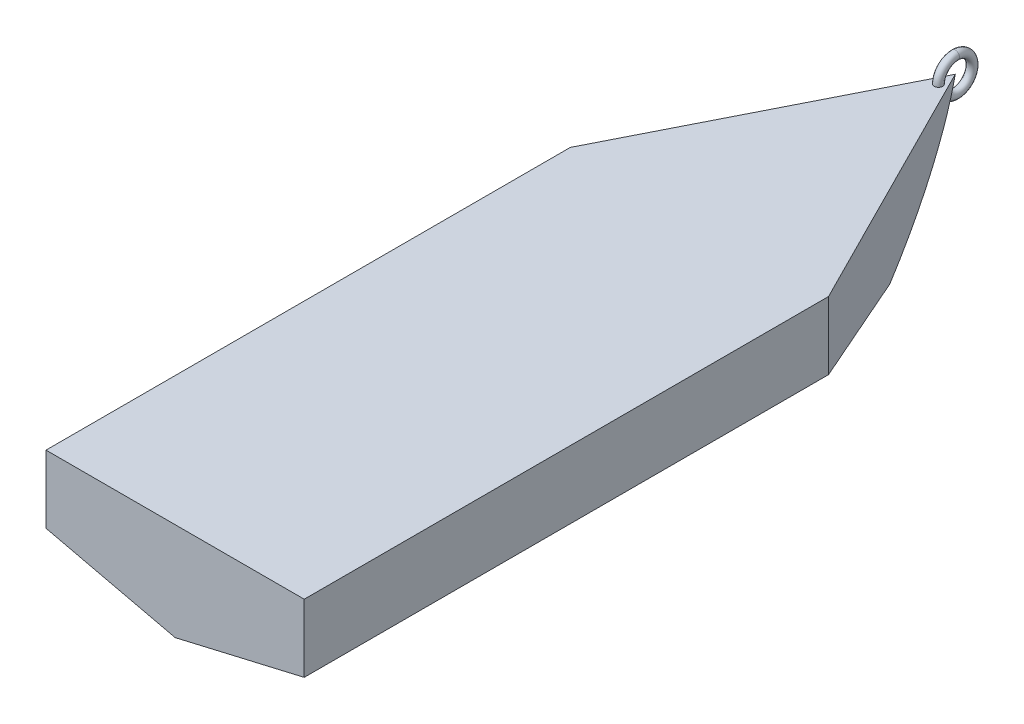
from build123d import *

# Parameters (mm, degrees)
TOP_BOW_EXTRUSION_DEPTH              = 56.86004
PORT_STARBOARD_CUT_DEPTH             = 38.529378828
PORT_STARBOARD_CUT_DEPTH_BACK        = 38.529527124
FORE_AFT_BOW_WRAPUP_EXTRUSTION_REACH = 76.36
SCALE_2_SCALE_X                      = 2
SCALE_2_SCALE_Y                      = 2
SCALE_2_SCALE_Z                      = 2
SHELL2_T                             = 2.54
SCALE1_SCALE_X                       = 0.65
SCALE1_SCALE_Y                       = 0.325
SCALE1_SCALE_Z                       = 0.65
SKETCH2_R                            = 1.5875


with BuildPart() as part:
    # Cross-Section C Sketch → Fore-Aft Loft section 0
    with BuildSketch(Plane.XY.offset(76.2)):
        Polygon((-0.000593186, -30.406404979), (37.528192355, -12.906444879), (37.528192355, 26.453635249), (-37.529378728, 26.453635249), (-37.529378728, -12.906444879), align=None)
    # Cross-Section B Sketch → Fore-Aft Loft section 1
    with BuildSketch(Plane.XY):
        Polygon((-0.000593186, -30.406404979), (37.528192355, -12.906444879), (37.528192355, 26.453635249), (-37.529378728, 26.453635249), (-37.529378728, -12.906444879), align=None)
    # Cross-Section A Sketch → Fore-Aft Loft section 2
    with BuildSketch(Plane(origin=(0, 0, -76.2), x_dir=(-1, 0, 0), z_dir=(0, 0, -1))):
        Polygon((-0.000593186, -30.406404979), (37.528192355, -12.906444879), (37.528192355, 26.453635249), (-37.529378728, 26.453635249), (-37.529378728, -12.906444879), align=None)
    loft()

    # Top Bow Profile → Top Bow Extrusion (add)
    with BuildSketch(Plane(origin=(0, 26.453635249, 0), x_dir=(1, 0, 0), z_dir=(0, 1, 0))):
        Polygon((37.529378728, 76.2), (0, 150.560276873), (-37.528192355, 76.2), align=None)
    extrude(amount=-TOP_BOW_EXTRUSION_DEPTH)

    # Port-Starboard Profile → Port-Starboard Cut (cut, two sides)
    with BuildSketch(Plane(origin=(0, 0, 0), x_dir=(0, 0, -1), z_dir=(1, 0, 0))) as port_starboard_cut_sk:
        with BuildLine():
            ThreePointArc((76.2, -30.406404979), (122.925878209, -14.460087823), (150.560276873, 26.453635249))
            Line((150.560276873, 26.453635249), (150.560276873, -30.406404979))
            Line((150.560276873, -30.406404979), (76.2, -30.406404979))
        make_face()
    extrude(amount=PORT_STARBOARD_CUT_DEPTH, mode=Mode.SUBTRACT)
    extrude(port_starboard_cut_sk.sketch, amount=-PORT_STARBOARD_CUT_DEPTH_BACK, mode=Mode.SUBTRACT)

    # Fore-Aft Bow Construction Sketch → Fore-aft bow wrapup extrustion (cut, up to next)
    with BuildSketch(Plane.XY.offset(-76.2), mode=Mode.PRIVATE) as fore_aft_bow_wrapup_extrustion_sk1:
        Polygon((0.000593186, -30.406404979), (37.529378728, -30.406404979), (37.529378728, -12.906444879), align=None)
    fore_aft_bow_wrapup_extrustion_tool1 = extrude(fore_aft_bow_wrapup_extrustion_sk1.sketch, amount=-FORE_AFT_BOW_WRAPUP_EXTRUSTION_REACH, mode=Mode.PRIVATE) & part.part
    add(fore_aft_bow_wrapup_extrustion_tool1.solids().sort_by_distance((25.019784, -24.573085, -76.2))[0], mode=Mode.SUBTRACT)
    # Fore-Aft Bow Construction Sketch → Fore-aft bow wrapup extrustion (cut, up to next)
    with BuildSketch(Plane.XY.offset(-76.2), mode=Mode.PRIVATE) as fore_aft_bow_wrapup_extrustion_sk2:
        Polygon((-37.528192355, -30.406404979), (0.000593186, -30.406404979), (-37.528192355, -12.906444879), align=None)
    fore_aft_bow_wrapup_extrustion_tool2 = extrude(fore_aft_bow_wrapup_extrustion_sk2.sketch, amount=-FORE_AFT_BOW_WRAPUP_EXTRUSTION_REACH, mode=Mode.PRIVATE) & part.part
    add(fore_aft_bow_wrapup_extrustion_tool2.solids().sort_by_distance((-25.018597, -24.573085, -76.2))[0], mode=Mode.SUBTRACT)


with BuildPart() as part_1:
    # Scale 2: scaled about (-0.000240035, 2.235376986, -18.845056047)
    add(part.part.scale((SCALE_2_SCALE_X, SCALE_2_SCALE_Y, SCALE_2_SCALE_Z), about=(-0.000240035, 2.235376986, -18.845056047)))

    # Shell2 (no face opened: a closed hollow body)
    add(offset(amount=-SHELL2_T, mode=Mode.PRIVATE), mode=Mode.SUBTRACT)


with BuildPart() as part_2:
    # Scale1: scaled about (-0.000206779, 4.134070729, -20.060024764)
    add(part_1.part.scale((SCALE1_SCALE_X, SCALE1_SCALE_Y, SCALE1_SCALE_Z), about=(-0.000206779, 4.134070729, -20.060024764)))

    # Sweep1: sweep along a path in Sketch1
    with BuildLine(Plane(origin=(0, 0, 0), x_dir=(0, 0, -1), z_dir=(1, 0, 0))) as sweep1_path:
        CenterArc((190.499879905, 19.258685868), 6.35, 0, 360)
    # Sketch2 → Sweep1 (sweep)
    with BuildSketch(Plane.XY.offset(-190.499879905)):
        with Locations((0, 25.608685868)):
            Circle(SKETCH2_R)
    sweep(path=sweep1_path.line)


solid = part_2.part
